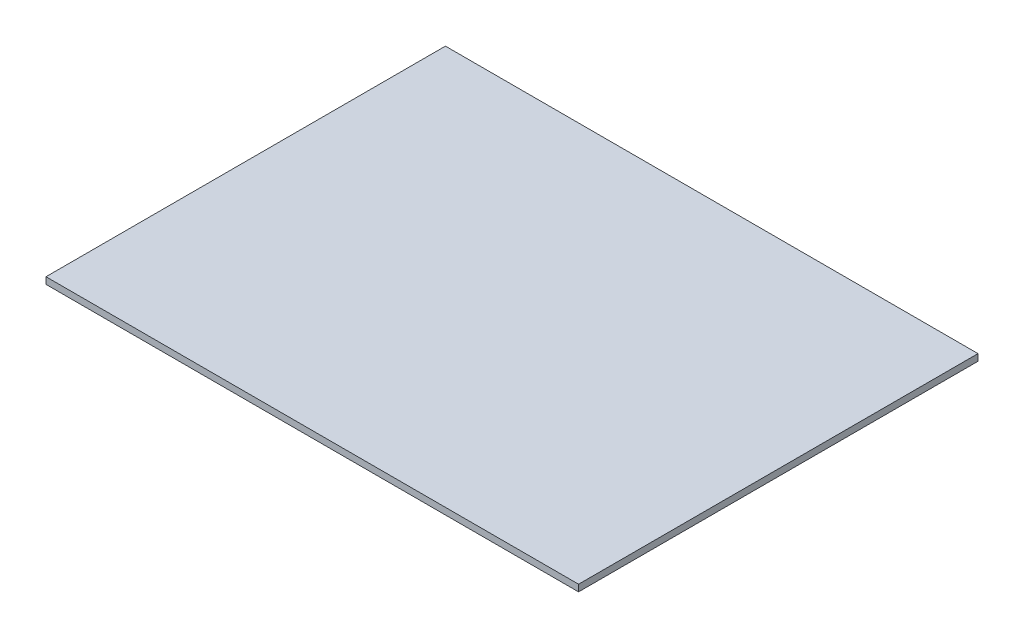
from build123d import *

# Parameters (mm, degrees)
ESQUISSE1_W        = 240
ESQUISSE1_H        = 180
BOSS_EXTRU_1_DEPTH = 3


with BuildPart() as part:
    # Esquisse1 → Boss.-Extru.1 (new body)
    with BuildSketch(Plane(origin=(0, 0, 0), x_dir=(1, 0, 0), z_dir=(0, 1, 0))):
        with Locations((120, 90)):
            Rectangle(ESQUISSE1_W, ESQUISSE1_H)
    extrude(amount=BOSS_EXTRU_1_DEPTH)


solid = part.part
